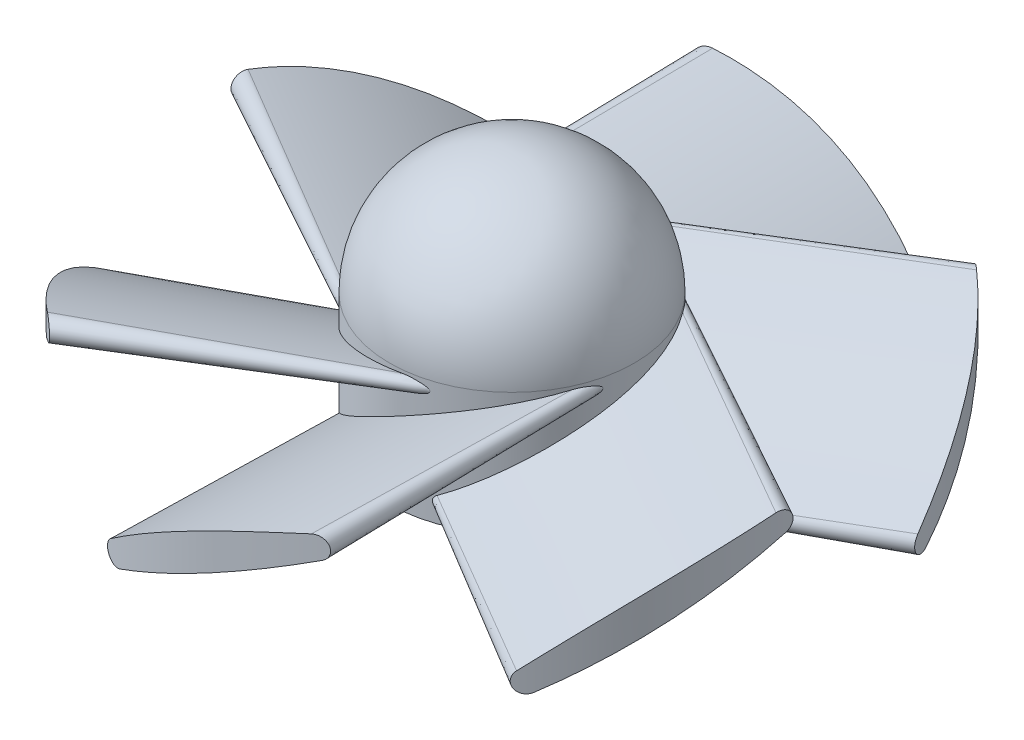
from build123d import *

# Parameters (mm, degrees)
BOSS_EXTRU_1_DEPTH                  = 30
BOSS_EXTRU_1_DRAFT                  = -1
R_P_TITION_CIRCULAIRE1_COPY_1_DEPTH = 30
R_P_TITION_CIRCULAIRE1_COPY_1_DRAFT = -1
R_P_TITION_CIRCULAIRE1_COPY_2_DEPTH = 30
R_P_TITION_CIRCULAIRE1_COPY_2_DRAFT = -1
R_P_TITION_CIRCULAIRE1_COPY_3_DEPTH = 30
R_P_TITION_CIRCULAIRE1_COPY_3_DRAFT = -1
R_P_TITION_CIRCULAIRE1_COPY_4_DEPTH = 30
R_P_TITION_CIRCULAIRE1_COPY_4_DRAFT = -1
R_P_TITION_CIRCULAIRE1_COPY_5_DEPTH = 30
R_P_TITION_CIRCULAIRE1_COPY_5_DRAFT = -1
ESQUISSE3_OUTSIDE_W                 = 77.786
ESQUISSE3_OUTSIDE_H                 = 79
ESQUISSE3_OUTSIDE_R                 = 17.5
ENL_V_MAT_EXTRU_1_DEPTH             = 44.965034361


with BuildPart() as part:
    # Esquisse1 → Révolution1 (revolve)
    with BuildSketch(Plane.XY):
        with BuildLine():
            Line((0, 0), (6.5, 0))
            Line((6.5, 0), (6.5, 6.5))
            ThreePointArc((6.5, 6.5), (4.596194078, 11.096194078), (0, 13))
            Line((0, 13), (0, 0))
        make_face()
    revolve(axis=Axis((0, 34.994921403, 0), (0, -1, 0)))


with BuildPart() as boss_extru_1_tool:
    # Esquisse2 → Boss.-Extru.1 (with draft: the straight prism first)
    with BuildSketch(Plane.XY):
        with BuildLine():
            Line((-3.865835921, 0.731671843), (6.134164079, 5.731671843))
            ThreePointArc((6.134164079, 5.731671843), (6.279809548, 6.108197119), (5.918738932, 6.288784762))
            ThreePointArc((5.918738932, 6.288784762), (0.62843786, 4.243124279), (-4.182271169, 1.238279712))
            ThreePointArc((-4.182271169, 1.238279712), (-4.254443424, 0.841070633), (-3.865835921, 0.731671843))
        make_face()
    extrude(amount=BOSS_EXTRU_1_DEPTH)
    # Boss.-Extru.1: the draft: its side faces are tilted about the plane it starts from
    boss_extru_1_sides = [boss_extru_1_tool.faces().sort_by_distance(p)[0] for p in [
        (-4.254443424, 0.841070633, 15),
        (1.134164079, 3.231671843, 15),
        (6.279809548, 6.108197119, 15),
        (0.62843786, 4.243124279, 15),
    ]]
    draft(boss_extru_1_sides, Plane.XY, BOSS_EXTRU_1_DRAFT)


with BuildPart() as part_1:
    add(part.part)

    # Boss.-Extru.1: add boss_extru_1_tool
    add(boss_extru_1_tool.part)


with BuildPart() as r_p_tition_circulaire1_copy_1_tool:
    # Répétition circulaire1 copy 1 sketch → Répétition circulaire1 copy 1 (with draft: the straight prism first)
    with BuildSketch(Plane(origin=(0, 0, 0), x_dir=(0.5000000000000001, 0, 0.8660254037844386), z_dir=(-0.8660254037844386, 0, 0.5000000000000001))):
        with BuildLine():
            Line((-3.865835921, 0.731671843), (6.134164079, 5.731671843))
            ThreePointArc((6.134164079, 5.731671843), (6.279809548, 6.108197119), (5.918738932, 6.288784762))
            ThreePointArc((5.918738932, 6.288784762), (0.62843786, 4.243124279), (-4.182271169, 1.238279712))
            ThreePointArc((-4.182271169, 1.238279712), (-4.254443424, 0.841070633), (-3.865835921, 0.731671843))
        make_face()
    extrude(amount=R_P_TITION_CIRCULAIRE1_COPY_1_DEPTH)
    # Répétition circulaire1 copy 1: the draft: its side faces are tilted about the plane it starts from
    r_p_tition_circulaire1_copy_1_sides = [r_p_tition_circulaire1_copy_1_tool.faces().sort_by_distance(p)[0] for p in [
        (-15.117602769, 0.841070633, 3.815543916),
        (-12.423299017, 3.231671843, 8.482214904),
        (-9.850476283, 6.108197119, 12.938474599),
        (-12.676162127, 4.243124279, 8.044243151),
    ]]
    draft(r_p_tition_circulaire1_copy_1_sides, Plane(origin=(0, 0, 0), x_dir=(0.5000000000000001, 0, 0.8660254037844386), z_dir=(-0.8660254037844386, 0, 0.5000000000000001)), R_P_TITION_CIRCULAIRE1_COPY_1_DRAFT)


with BuildPart() as part_2:
    add(part_1.part)

    # Répétition circulaire1 copy 1: add r_p_tition_circulaire1_copy_1_tool
    add(r_p_tition_circulaire1_copy_1_tool.part)


with BuildPart() as r_p_tition_circulaire1_copy_2_tool:
    # Répétition circulaire1 copy 2 sketch → Répétition circulaire1 copy 2 (with draft: the straight prism first)
    with BuildSketch(Plane(origin=(0, 0, 0), x_dir=(-0.4999999999999998, 0, 0.8660254037844387), z_dir=(-0.8660254037844387, 0, -0.4999999999999998))):
        with BuildLine():
            Line((-3.865835921, 0.731671843), (6.134164079, 5.731671843))
            ThreePointArc((6.134164079, 5.731671843), (6.279809548, 6.108197119), (5.918738932, 6.288784762))
            ThreePointArc((5.918738932, 6.288784762), (0.62843786, 4.243124279), (-4.182271169, 1.238279712))
            ThreePointArc((-4.182271169, 1.238279712), (-4.254443424, 0.841070633), (-3.865835921, 0.731671843))
        make_face()
    extrude(amount=R_P_TITION_CIRCULAIRE1_COPY_2_DEPTH)
    # Répétition circulaire1 copy 2: the draft: its side faces are tilted about the plane it starts from
    r_p_tition_circulaire1_copy_2_sides = [r_p_tition_circulaire1_copy_2_tool.faces().sort_by_distance(p)[0] for p in [
        (-10.863159345, 0.841070633, -11.184456084),
        (-13.557463096, 3.231671843, -6.517785096),
        (-16.130285831, 6.108197119, -2.061525401),
        (-13.304599987, 4.243124279, -6.955756849),
    ]]
    draft(r_p_tition_circulaire1_copy_2_sides, Plane(origin=(0, 0, 0), x_dir=(-0.4999999999999998, 0, 0.8660254037844387), z_dir=(-0.8660254037844387, 0, -0.4999999999999998)), R_P_TITION_CIRCULAIRE1_COPY_2_DRAFT)


with BuildPart() as part_3:
    add(part_2.part)

    # Répétition circulaire1 copy 2: add r_p_tition_circulaire1_copy_2_tool
    add(r_p_tition_circulaire1_copy_2_tool.part)


with BuildPart() as r_p_tition_circulaire1_copy_3_tool:
    # Répétition circulaire1 copy 3 sketch → Répétition circulaire1 copy 3 (with draft: the straight prism first)
    with BuildSketch(Plane(origin=(0, 0, 0), x_dir=(-1, 0, 0), z_dir=(0, 0, -1))):
        with BuildLine():
            Line((-3.865835921, 0.731671843), (6.134164079, 5.731671843))
            ThreePointArc((6.134164079, 5.731671843), (6.279809548, 6.108197119), (5.918738932, 6.288784762))
            ThreePointArc((5.918738932, 6.288784762), (0.62843786, 4.243124279), (-4.182271169, 1.238279712))
            ThreePointArc((-4.182271169, 1.238279712), (-4.254443424, 0.841070633), (-3.865835921, 0.731671843))
        make_face()
    extrude(amount=R_P_TITION_CIRCULAIRE1_COPY_3_DEPTH)
    # Répétition circulaire1 copy 3: the draft: its side faces are tilted about the plane it starts from
    r_p_tition_circulaire1_copy_3_sides = [r_p_tition_circulaire1_copy_3_tool.faces().sort_by_distance(p)[0] for p in [
        (4.254443424, 0.841070633, -15),
        (-1.134164079, 3.231671843, -15),
        (-6.279809548, 6.108197119, -15),
        (-0.62843786, 4.243124279, -15),
    ]]
    draft(r_p_tition_circulaire1_copy_3_sides, Plane(origin=(0, 0, 0), x_dir=(-1, 0, 0), z_dir=(0, 0, -1)), R_P_TITION_CIRCULAIRE1_COPY_3_DRAFT)


with BuildPart() as part_4:
    add(part_3.part)

    # Répétition circulaire1 copy 3: add r_p_tition_circulaire1_copy_3_tool
    add(r_p_tition_circulaire1_copy_3_tool.part)


with BuildPart() as r_p_tition_circulaire1_copy_4_tool:
    # Répétition circulaire1 copy 4 sketch → Répétition circulaire1 copy 4 (with draft: the straight prism first)
    with BuildSketch(Plane(origin=(0, 0, 0), x_dir=(-0.5000000000000004, 0, -0.8660254037844384), z_dir=(0.8660254037844384, 0, -0.5000000000000004))):
        with BuildLine():
            Line((-3.865835921, 0.731671843), (6.134164079, 5.731671843))
            ThreePointArc((6.134164079, 5.731671843), (6.279809548, 6.108197119), (5.918738932, 6.288784762))
            ThreePointArc((5.918738932, 6.288784762), (0.62843786, 4.243124279), (-4.182271169, 1.238279712))
            ThreePointArc((-4.182271169, 1.238279712), (-4.254443424, 0.841070633), (-3.865835921, 0.731671843))
        make_face()
    extrude(amount=R_P_TITION_CIRCULAIRE1_COPY_4_DEPTH)
    # Répétition circulaire1 copy 4: the draft: its side faces are tilted about the plane it starts from
    r_p_tition_circulaire1_copy_4_sides = [r_p_tition_circulaire1_copy_4_tool.faces().sort_by_distance(p)[0] for p in [
        (15.117602769, 0.841070633, -3.815543916),
        (12.423299017, 3.231671843, -8.482214904),
        (9.850476283, 6.108197119, -12.938474599),
        (12.676162127, 4.243124279, -8.044243151),
    ]]
    draft(r_p_tition_circulaire1_copy_4_sides, Plane(origin=(0, 0, 0), x_dir=(-0.5000000000000004, 0, -0.8660254037844384), z_dir=(0.8660254037844384, 0, -0.5000000000000004)), R_P_TITION_CIRCULAIRE1_COPY_4_DRAFT)


with BuildPart() as part_5:
    add(part_4.part)

    # Répétition circulaire1 copy 4: add r_p_tition_circulaire1_copy_4_tool
    add(r_p_tition_circulaire1_copy_4_tool.part)


with BuildPart() as r_p_tition_circulaire1_copy_5_tool:
    # Répétition circulaire1 copy 5 sketch → Répétition circulaire1 copy 5 (with draft: the straight prism first)
    with BuildSketch(Plane(origin=(0, 0, 0), x_dir=(0.5000000000000001, 0, -0.8660254037844386), z_dir=(0.8660254037844386, 0, 0.5000000000000001))):
        with BuildLine():
            Line((-3.865835921, 0.731671843), (6.134164079, 5.731671843))
            ThreePointArc((6.134164079, 5.731671843), (6.279809548, 6.108197119), (5.918738932, 6.288784762))
            ThreePointArc((5.918738932, 6.288784762), (0.62843786, 4.243124279), (-4.182271169, 1.238279712))
            ThreePointArc((-4.182271169, 1.238279712), (-4.254443424, 0.841070633), (-3.865835921, 0.731671843))
        make_face()
    extrude(amount=R_P_TITION_CIRCULAIRE1_COPY_5_DEPTH)
    # Répétition circulaire1 copy 5: the draft: its side faces are tilted about the plane it starts from
    r_p_tition_circulaire1_copy_5_sides = [r_p_tition_circulaire1_copy_5_tool.faces().sort_by_distance(p)[0] for p in [
        (10.863159345, 0.841070633, 11.184456084),
        (13.557463096, 3.231671843, 6.517785096),
        (16.130285831, 6.108197119, 2.061525401),
        (13.304599987, 4.243124279, 6.955756849),
    ]]
    draft(r_p_tition_circulaire1_copy_5_sides, Plane(origin=(0, 0, 0), x_dir=(0.5000000000000001, 0, -0.8660254037844386), z_dir=(0.8660254037844386, 0, 0.5000000000000001)), R_P_TITION_CIRCULAIRE1_COPY_5_DRAFT)


with BuildPart() as part_6:
    add(part_5.part)

    # Répétition circulaire1 copy 5: add r_p_tition_circulaire1_copy_5_tool
    add(r_p_tition_circulaire1_copy_5_tool.part)

    # Esquisse3 outside → Enlèv. mat.-Extru.1 (cut, through all)
    with BuildSketch(Plane(origin=(0, 0, 0), x_dir=(1, 0, 0), z_dir=(0, 1, 0))):
        Rectangle(ESQUISSE3_OUTSIDE_W, ESQUISSE3_OUTSIDE_H)
        Circle(ESQUISSE3_OUTSIDE_R, mode=Mode.SUBTRACT)
    extrude(amount=ENL_V_MAT_EXTRU_1_DEPTH, mode=Mode.SUBTRACT)


solid = part_6.part
